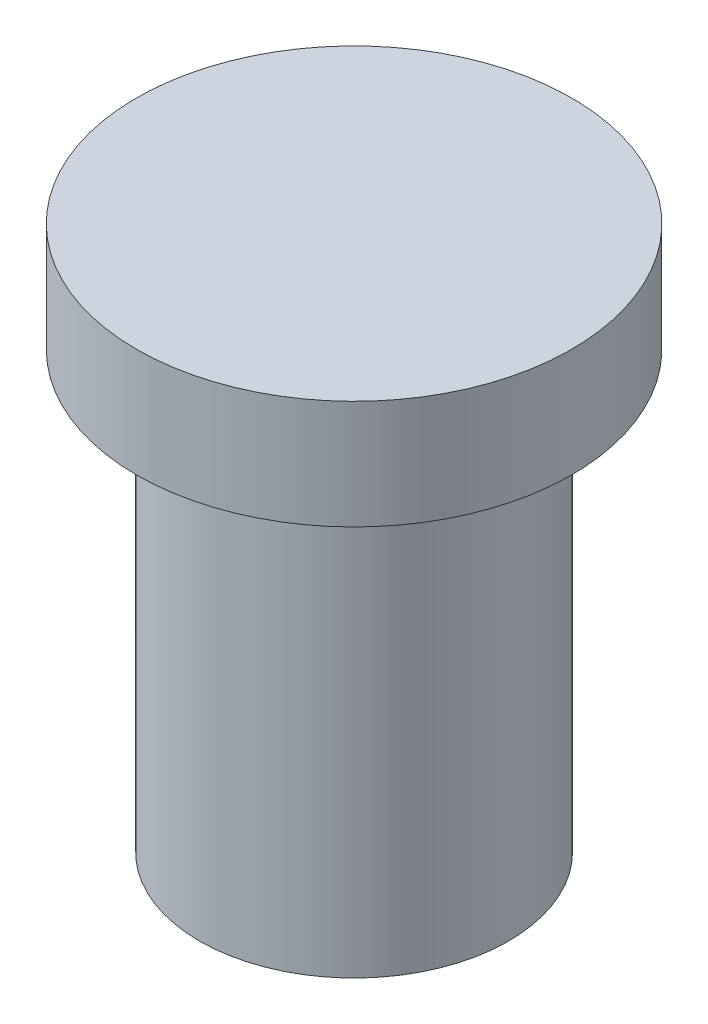
from build123d import *

# Parameters (mm, degrees)
SKETCH1_R           = 3.55
BOSS_EXTRUDE1_DEPTH = 10
SKETCH2_R           = 5
BOSS_EXTRUDE2_DEPTH = 2.5


with BuildPart() as part:
    # Sketch1 → Boss-Extrude1 (new body)
    with BuildSketch(Plane(origin=(0, 0, 0), x_dir=(1, 0, 0), z_dir=(0, 1, 0))):
        Circle(SKETCH1_R)
    extrude(amount=BOSS_EXTRUDE1_DEPTH)

    # Sketch2 → Boss-Extrude2 (add)
    with BuildSketch(Plane(origin=(0, 10, 0), x_dir=(1, 0, 0), z_dir=(0, 1, 0))):
        Circle(SKETCH2_R)
    extrude(amount=BOSS_EXTRUDE2_DEPTH)


solid = part.part
